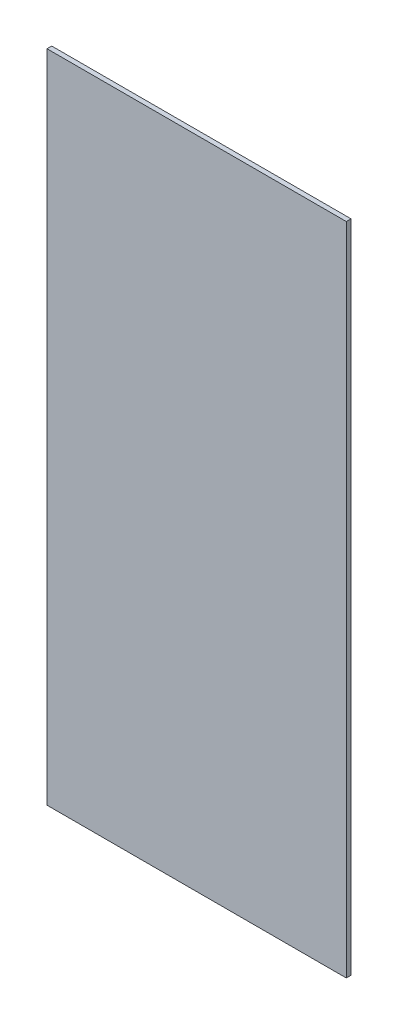
from build123d import *

# Parameters (mm, degrees)
SKETCH2_W           = 103.2512
SKETCH2_H           = 226
BOSS_EXTRUDE1_DEPTH = 1.6256


with BuildPart() as part:
    # Sketch2 → Boss-Extrude1 (new body)
    with BuildSketch(Plane.XY):
        Rectangle(SKETCH2_W, SKETCH2_H)
    extrude(amount=BOSS_EXTRUDE1_DEPTH)


solid = part.part
